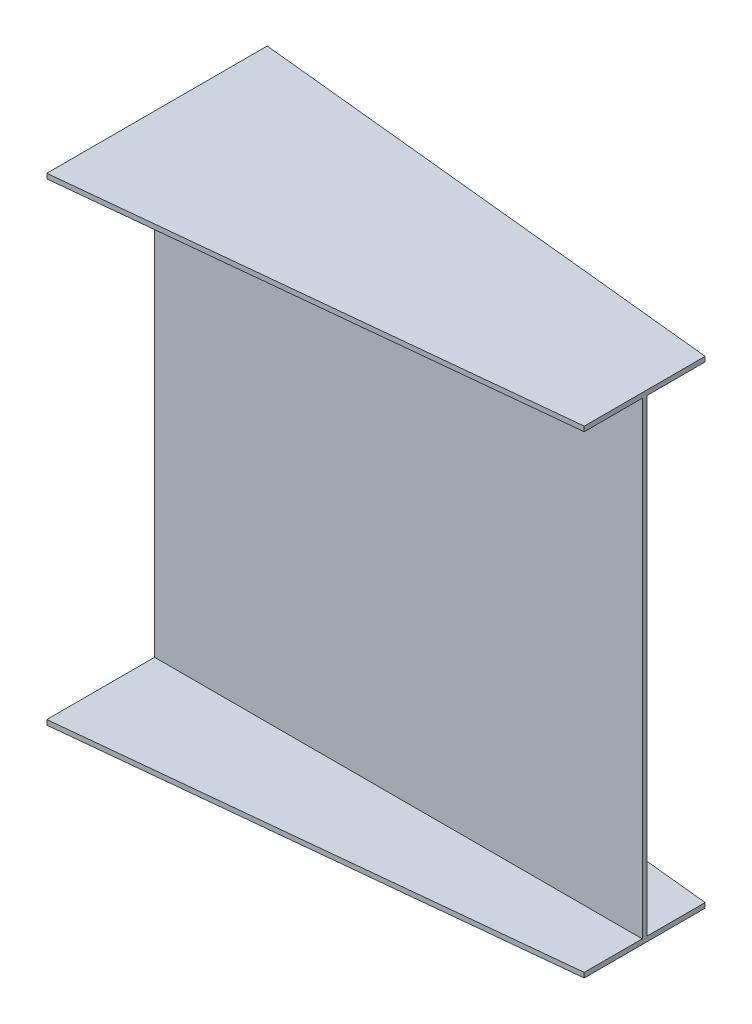
from build123d import *


with BuildPart() as part:
    # Sketch1 → Loft l2 section 0
    with BuildSketch(Plane(origin=(0, 0, 0), x_dir=(0, 0, -1), z_dir=(1, 0, 0))):
        Polygon((-231, 490), (221, 490), (221, 480), (0, 480), (0, -480), (221, -480), (221, -490), (-231, -490), (-231, -480), (-10, -480), (-10, 480), (-231, 480), align=None)
    # Sketch4 → Loft l2 section 1
    with BuildSketch(Plane(origin=(1000, 0, -1000), x_dir=(0, 0, 1), z_dir=(-1, 0, 0))):
        Polygon((881, 490), (1129, 490), (1129, 480), (1010, 480), (1010, -480), (1129, -480), (1129, -490), (881, -490), (881, -480), (1000, -480), (1000, 480), (881, 480), align=None)
    loft()


solid = part.part
